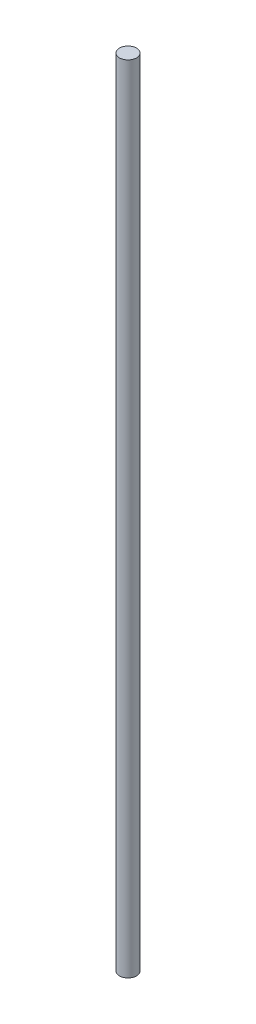
from build123d import *

# Parameters (mm, degrees)
SKETCH1_R           = 3
BOSS_EXTRUDE1_DEPTH = 139.7


with BuildPart() as part:
    # Sketch1 → Boss-Extrude1 (new body, symmetric)
    with BuildSketch(Plane(origin=(0, 0, 0), x_dir=(1, 0, 0), z_dir=(0, 1, 0))):
        Circle(SKETCH1_R)
    extrude(amount=BOSS_EXTRUDE1_DEPTH, both=True)


solid = part.part
